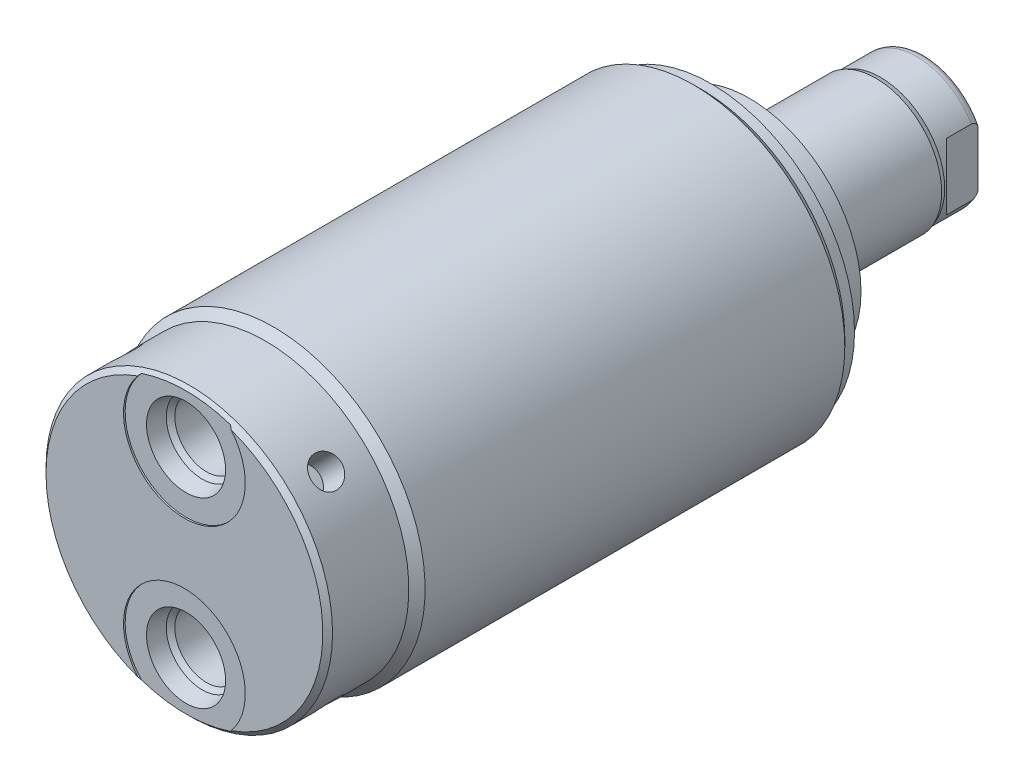
from build123d import *

# Parameters (mm, degrees)
SKETCH1_R          = 23.6855
EXTRUDE1_DEPTH     = 82.423
CHAMFER1_SIZE      = 0.762
SKETCH6_R          = 17.4625
EXTRUDE2_DEPTH     = 5.969
SKETCH7_W          = 27.178
SKETCH7_H          = 10.31875
CUT_EXTRUDE4_DEPTH = 19.84248
HOLE1_D            = 4.7498
HOLE1_DEPTH        = 4.7498
CIRPATTERN1_COUNT  = 4
LPATTERN1_COUNT    = 2
LPATTERN1_PITCH    = 28.5496


with BuildPart() as part:
    # Sketch1 → Extrude1 (new body)
    with BuildSketch(Plane.XY):
        Circle(SKETCH1_R)
    extrude(amount=EXTRUDE1_DEPTH)

    # Sketch2 → Cut-Revolve1 (revolve, cut)
    with BuildSketch(Plane(origin=(0, 0, 0), x_dir=(1, 0, 0), z_dir=(0, 1, 0)), mode=Mode.PRIVATE) as cut_revolve1_sk:
        Polygon((23.6855, -82.423), (23.6855, -68.453), (22.4155, -69.723), (22.4155, -82.423), align=None)
    revolve(cut_revolve1_sk.sketch.rotate(Axis((0, 0, 0), (0, 0, 1)), 180), axis=Axis((0, 0, 0), (0, 0, 1)), mode=Mode.SUBTRACT)  # turned: the seam where the file's is

    # Sketch3 → Cut-Revolve2 (revolve, cut)
    with BuildSketch(Plane(origin=(0, 0, 0), x_dir=(1, 0, 0), z_dir=(0, 1, 0)), mode=Mode.PRIVATE) as cut_revolve2_sk:
        Polygon((22.4155, 0), (22.4155, -1.524), (23.6855, -2.794), (23.6855, 0), align=None)
    revolve(cut_revolve2_sk.sketch.rotate(Axis((0, 0, 0), (0, 0, -1)), 180), axis=Axis((0, 0, 0), (0, 0, -1)), mode=Mode.SUBTRACT)  # turned: the seam where the file's is

    # Chamfer1
    chamfer1_edges = [part.edges().sort_by_distance(p)[0] for p in [
        (22.4155, 0, 82.423),
    ]]
    chamfer(chamfer1_edges, length=CHAMFER1_SIZE)

    # S2D0002 → Cut-Revolve3 (revolve, cut)
    with BuildSketch(Plane(origin=(0, 0, 0), x_dir=(0, -1, 0), z_dir=(1, 0, 0)), mode=Mode.PRIVATE) as cut_revolve3_sk:
        Polygon((20.4597, -82.169), (23.7998, -82.169), (23.7998, -82.423), (14.2748, -82.423), (14.2748, -68.199), (19.2532, -68.199), (19.2532, -78.952393135), (19.917106865, -79.6163), align=None)
    cut_revolve3 = revolve(cut_revolve3_sk.sketch.rotate(Axis((0, -14.2748, 14.6685), (0, 0, -1)), 270), axis=Axis((0, -14.2748, 14.6685), (0, 0, -1)), mode=Mode.SUBTRACT)  # turned: the seam where the file's is

    # Sketch6 → Extrude2 (add)
    with BuildSketch(Plane(origin=(0, 0, 0), x_dir=(-1, 0, 0), z_dir=(0, 0, -1))):
        with Locations(Location((0, 0, 0), (0, 0, 180))):  # turned: the seam where the file's is
            Circle(SKETCH6_R)
    extrude(amount=EXTRUDE2_DEPTH)

    # Sketch7 → Revolve1 (revolve)
    with BuildSketch(Plane(origin=(0, 0, 0), x_dir=(0, 0, -1), z_dir=(1, 0, 0)), mode=Mode.PRIVATE) as revolve1_sk:
        with Locations((19.558, -5.159375)):
            Rectangle(SKETCH7_W, SKETCH7_H)
    revolve(revolve1_sk.sketch.rotate(Axis((0, 0, 0), (0, 0, -1)), 90), axis=Axis((0, 0, 0), (0, 0, -1)))  # turned: the seam where the file's is

    # S2D0001 → Cut-Revolve5 (revolve, cut)
    with BuildSketch(Plane(origin=(0, 0, 0), x_dir=(1, 0, 0), z_dir=(0, 1, 0))):
        Polygon((3.2639, 31.211260017), (3.2639, 18.2118), (0, 18.2118), (0, 33.147), (4.3815, 33.147), align=None)
    revolve(axis=Axis((0, 0, 31.308359971), (0, 0, -1)), mode=Mode.SUBTRACT)

    # Sketch9 → Cut-Revolve6 (revolve, cut)
    with BuildSketch(Plane(origin=(0, 0, 0), x_dir=(0, -1, 0), z_dir=(1, 0, 0)), mode=Mode.PRIVATE) as cut_revolve6_sk:
        with BuildLine():
            Line((-10.31875, 25.7302), (-10.033, 26.4922))
            Line((-10.033, 26.4922), (-10.033, 32.131))
            ThreePointArc((-10.033, 32.131), (-9.932678675, 32.674796865), (-9.644922533, 33.147))
            Line((-9.644922533, 33.147), (-10.31875, 33.147))
            Line((-10.31875, 33.147), (-10.31875, 25.7302))
        make_face()
    revolve(cut_revolve6_sk.sketch.rotate(Axis((0, 0, -12.65936), (0, 0, -1)), 90), axis=Axis((0, 0, -12.65936), (0, 0, -1)), mode=Mode.SUBTRACT)  # turned: the seam where the file's is

    # Sketch13 → Cut-Extrude4 (cut, symmetric)
    with BuildSketch(Plane(origin=(0, 0, 0), x_dir=(1, 0, 0), z_dir=(0, 1, 0))):
        Polygon((8.5852, 33.147), (8.5852, 28.194), (10.033, 26.7462), (10.033, 33.147), align=None)
        Polygon((-8.5852, 33.147), (-8.5852, 28.194), (-10.033, 26.7462), (-10.033, 33.147), align=None)
    extrude(amount=CUT_EXTRUDE4_DEPTH, both=True, mode=Mode.SUBTRACT)

    # Hole1
    with Locations(Plane(origin=(-15.850152054, 15.850152054, 76.073), x_dir=(0.707106781, 0.707106781, 0), z_dir=(-0.707106781, 0.707106781, 0))):
        with Locations((0, 0)):
            hole1 = Hole(HOLE1_D / 2, depth=HOLE1_DEPTH)

    # CirPattern1: Hole1 ×4 about axis
    cirpattern1_axis = Axis((0, 0, 0), (0, 0, 1))
    for i in range(1, CIRPATTERN1_COUNT):
        add(hole1.rotate(cirpattern1_axis, i * 360 / CIRPATTERN1_COUNT), mode=Mode.SUBTRACT)

    # LPattern1: Cut-Revolve3 ×2
    with Locations(*[(0, i * LPATTERN1_PITCH, 0) for i in range(1, LPATTERN1_COUNT)]):
        add(cut_revolve3, mode=Mode.SUBTRACT)


solid = part.part
